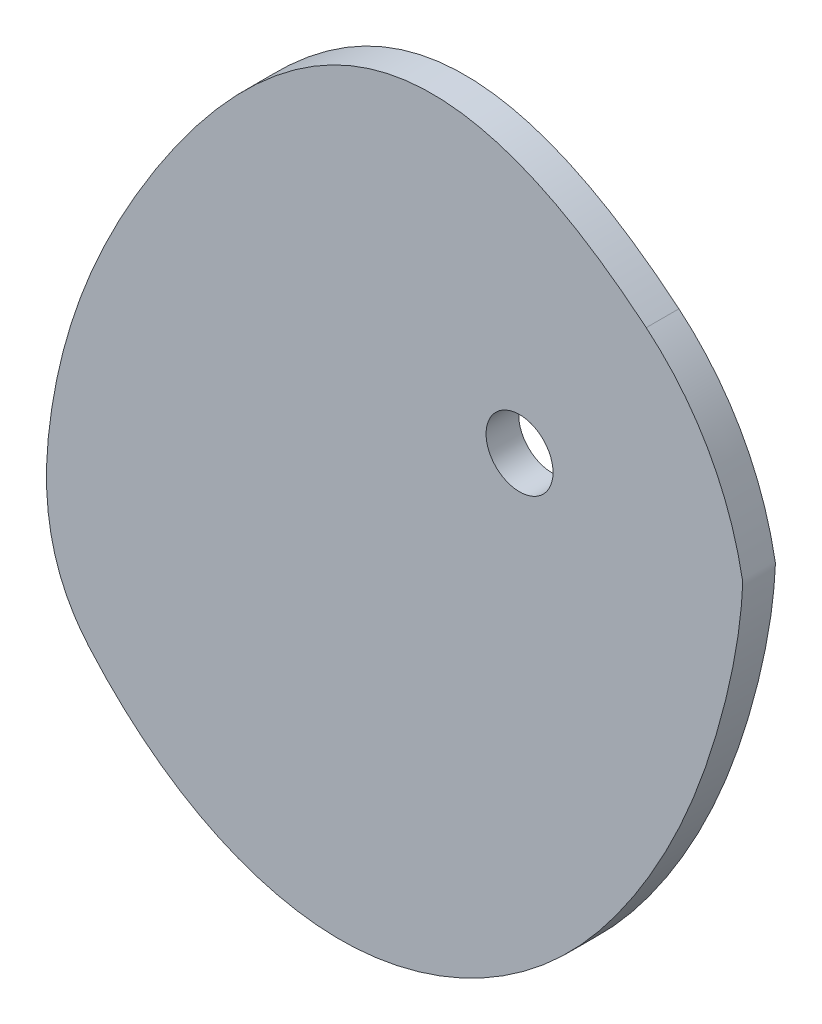
from build123d import *

# Parameters (mm, degrees)
SKETCH1_R           = 3.075
BOSS_EXTRUDE1_DEPTH = 1.5


with BuildPart() as part:
    # Sketch1 → Boss-Extrude1 (new body, symmetric)
    with BuildSketch(Plane.XY):
        with BuildLine():
            add(Edge.make_bspline(
                [(11.634950811, 15.800321449), (0.028055904, 25.434294376), (-17.414020712, 27.248955021), (-35.895046658, 4.24235475), (-43.985427464, -15.828375506), (-43.784510858, -30.273405058), (-39.554444487, -35.146298118)],
                knots=[0, 0, 0, 0, 0.309251015, 0.582243378, 0.82001673, 1, 1, 1, 1], degree=3))
            add(Edge.make_bspline(
                [(-39.554444487, -35.146298118), (-39.358922613, -35.371532689), (-38.954086034, -35.828491757), (-38.327635377, -36.506087428), (-37.676443606, -37.179690264), (-37.009872208, -37.838353001), (-36.327930242, -38.48126825), (-35.63066602, -39.107612546), (-34.918167988, -39.716547883), (-34.190565543, -40.307223272), (-33.448029808, -40.878776337), (-32.69077435, -41.430334943), (-31.919055845, -41.961018846), (-31.133174691, -42.469941367), (-30.333475559, -42.956211101), (-29.520347896, -43.418933639), (-28.694226366, -43.857213315), (-27.855591239, -44.270154972), (-27.004968714, -44.656865748), (-26.142931193, -45.016456876), (-25.270097493, -45.348045498), (-24.387132993, -45.650756494), (-23.494749731, -45.923724325), (-22.593706438, -46.166094878), (-21.684808505, -46.377027339), (-20.768907906, -46.555695997), (-19.846903022, -46.701292365), (-18.919738523, -46.813026108), (-17.988404773, -46.890130465), (-17.053938685, -46.931850896), (-16.117432397, -46.937496322), (-15.180157109, -46.906262664), (-14.243541344, -46.838649178), (-13.309071096, -46.735482538), (-12.378226911, -46.597574573), (-11.452431472, -46.425809499), (-10.533049478, -46.221116988), (-9.621385604, -45.98447621), (-8.718683135, -45.716911513), (-7.826122528, -45.419490281), (-6.944820113, -45.093320168), (-6.075826863, -44.739546437), (-5.220127265, -44.359349237), (-4.378638282, -43.953940845), (-3.55220841, -43.524562882), (-2.741616825, -43.072483508), (-1.94757263, -42.59899458), (-1.170714201, -42.105408801), (-0.41160862, -41.593056844), (0.329248782, -41.063284469), (1.051434793, -40.517449617), (1.754598588, -39.956919504), (2.438461896, -39.383067709), (3.102819072, -38.797271252), (3.747537066, -38.200907678), (4.3725553, -37.595352143), (4.977885444, -36.981974506), (5.56361109, -36.362136423), (6.129887339, -35.737188467), (6.67694027, -35.10846724), (7.205066378, -34.477292547), (7.714631687, -33.844964441), (8.206071606, -33.212760844), (8.679887632, -32.581933137), (9.136655133, -31.953709323), (9.57699457, -31.329263633), (10.001748031, -30.709702111), (10.672895353, -29.703750915), (11.428525518, -28.508519974), (12.246317889, -27.124744933), (12.891237389, -25.973983265), (13.489692778, -24.84854664), (14.044959248, -23.748686352), (14.560186323, -22.674451737), (15.113664214, -21.460614522), (15.690659132, -20.114221695), (16.337692502, -18.490193148), (16.913259904, -16.921226819), (17.426730101, -15.404851168), (17.797865963, -14.233065689), (18.097016774, -13.23519842), (18.336075796, -12.402072423), (18.560568704, -11.584453827), (18.771491613, -10.781040119), (18.969668489, -9.990523568), (19.15575465, -9.211604238), (19.33024123, -8.443002714), (19.493460418, -7.683472363), (19.64559148, -6.93181113), (19.786667504, -6.186872813), (19.91658284, -5.447577787), (20.03510119, -4.712923134), (20.141864281, -3.981992149), (20.236400807, -3.253963203), (20.304581333, -2.648458676), (20.352371994, -2.165015202), (20.384674543, -1.803139053), (20.413598625, -1.441516308), (20.438222822, -1.080157274), (20.461501026, -0.718796446), (20.47192834, -0.358233383), (20.512193391, 0.007583611), (20.420294325, 0.366282304), (20.358204341, 0.727998489), (20.282605136, 1.086406254), (20.205316122, 1.442283779), (20.123259308, 1.795424153), (20.037316797, 2.14588286), (19.887962015, 2.722982176), (19.59669815, 3.742230413), (19.144722314, 5.067911953), (18.581419243, 6.456455163), (18.005560921, 7.69265439), (17.374399513, 8.885317521), (16.689168578, 10.033912511), (15.950881261, 11.137645383), (15.160392762, 12.195428176), (14.318466864, 13.205858223), (13.425843473, 14.16720628), (12.530077513, 15.032247758), (11.920778524, 15.563078287), (11.634950811, 15.800321449)],
                knots=[0.561512544, 0.561512544, 0.561512544, 0.561512544, 0.565782528, 0.570252105, 0.57472292, 0.579194639, 0.583666924, 0.588139439, 0.592611855, 0.597083853, 0.601555132, 0.606025412, 0.610494439, 0.614961992, 0.619427887, 0.623891985, 0.628354194, 0.632814475, 0.637272853, 0.641729416, 0.646184326, 0.650637823, 0.655090233, 0.659541971, 0.663993554, 0.668445597, 0.672898832, 0.677354104, 0.681812384, 0.68627477, 0.690742499, 0.695216754, 0.699697325, 0.704183213, 0.708673274, 0.713166232, 0.71766069, 0.722155137, 0.726647962, 0.731137456, 0.735621826, 0.7400992, 0.744567632, 0.749025113, 0.753469575, 0.757898896, 0.762310907, 0.766703399, 0.771074124, 0.775420805, 0.779741136, 0.784032793, 0.788293433, 0.792520702, 0.796712241, 0.800865688, 0.804978687, 0.809048891, 0.813073968, 0.817051612, 0.820979544, 0.824855525, 0.82867736, 0.832442913, 0.836150111, 0.839796963, 0.843381676, 0.84690413, 0.857109335, 0.863622561, 0.86991433, 0.875993807, 0.881870128, 0.887552392, 0.893049665, 0.900968457, 0.908521612, 0.918075538, 0.924891611, 0.931440483, 0.935671971, 0.939805498, 0.943849063, 0.947810449, 0.95169719, 0.955516554, 0.959275508, 0.962980703, 0.966638443, 0.970254675, 0.973834969, 0.977384508, 0.980908081, 0.984410078, 0.987894493, 0.989631248, 0.991364926, 0.993095918, 0.994824589, 0.996551283, 0.998276321, 1, 1.001764203, 1.003519492, 1.005266096, 1.007004244, 1.008734164, 1.010456082, 1.01217022, 1.017268173, 1.025629542, 1.032212071, 1.038713875, 1.045147285, 1.05152405, 1.057855307, 1.064151567, 1.070422701, 1.076677929, 1.082925818, 1.088243786, 1.088243786, 1.088243786, 1.088243786], degree=3))
        make_face()
        Circle(SKETCH1_R, mode=Mode.SUBTRACT)
    extrude(amount=BOSS_EXTRUDE1_DEPTH, both=True)


solid = part.part
